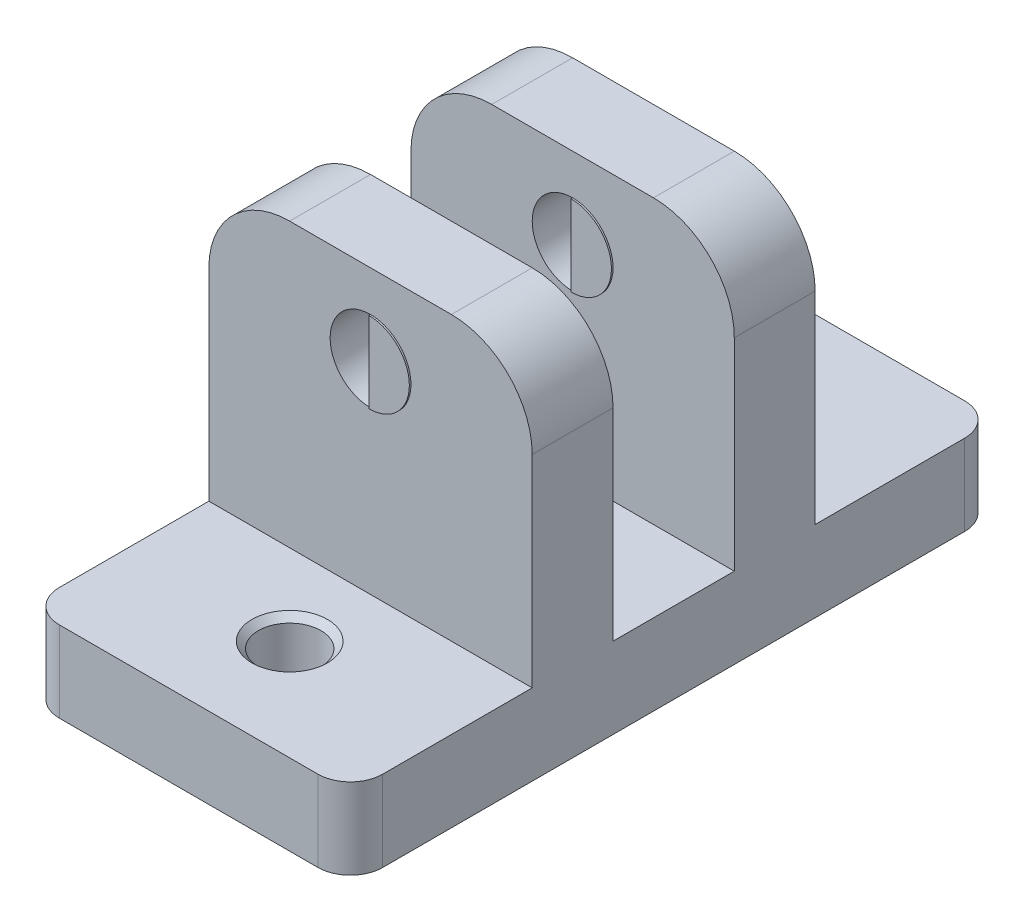
from build123d import *

# Parameters (mm, degrees)
SKETCH2_W                        = 25.4
SKETCH2_H                        = 50.8
BOSS_EXTRUDE2_DEPTH              = 28.575
SKETCH3_W                        = 14.2875
SKETCH3_H                        = 22.225
SKETCH3_W_2                      = 9.525
CUT_EXTRUDE1_DEPTH               = 26.4
F_10_0_1935_DIAMETER_HOLE1_D     = 4.9149
F_10_0_1935_DIAMETER_HOLE1_DEPTH = 6.35
F_10_0_1935_DIAMETER_HOLE1_TIP   = 1.476584928
SKETCH8_R                        = 3.175
CUT_EXTRUDE3_DEPTH               = 37.5125
FILLET1_R                        = 6.35
FILLET2_R                        = 2.54
CHAMFER1_SIZE                    = 0.508
BOSS_EXTRUDE3_DEPTH              = 3.302


with BuildPart() as part:
    # Sketch2 → Boss-Extrude2 (new body)
    with BuildSketch(Plane(origin=(0, 0, 0), x_dir=(1, 0, 0), z_dir=(0, 1, 0))):
        Rectangle(SKETCH2_W, SKETCH2_H)
    extrude(amount=BOSS_EXTRUDE2_DEPTH)

    # Sketch3 → Cut-Extrude1 (cut, through all)
    with BuildSketch(Plane(origin=(12.7, 0, 0), x_dir=(0, 0, -1), z_dir=(1, 0, 0))):
        with Locations((-18.25625, 17.4625)):
            Rectangle(SKETCH3_W, SKETCH3_H)
        with Locations((18.25625, 17.4625)):
            Rectangle(SKETCH3_W, SKETCH3_H)
        with Locations((0, 17.4625)):
            Rectangle(SKETCH3_W_2, SKETCH3_H)
    extrude(amount=-CUT_EXTRUDE1_DEPTH, mode=Mode.SUBTRACT)

    # #10 (0.1935) Diameter Hole1
    with Locations(Plane(origin=(0, 6.35, 0), x_dir=(1, 0, 0), z_dir=(0, 1, 0))):
        with Locations((0, -17.4625), (0, 17.4625)):
            Hole(F_10_0_1935_DIAMETER_HOLE1_D / 2, depth=F_10_0_1935_DIAMETER_HOLE1_DEPTH)
            with Locations((0, 0, -(F_10_0_1935_DIAMETER_HOLE1_DEPTH + F_10_0_1935_DIAMETER_HOLE1_TIP / 2))):  # 118° drill point
                Cone(0, F_10_0_1935_DIAMETER_HOLE1_D / 2, F_10_0_1935_DIAMETER_HOLE1_TIP, mode=Mode.SUBTRACT)

    # Sketch8 → Cut-Extrude3 (cut, through all)
    with BuildSketch(Plane(origin=(0, 0, -11.1125), x_dir=(-1, 0, 0), z_dir=(0, 0, -1))):
        with Locations((0, 22.225)):
            Circle(SKETCH8_R)
    extrude(amount=-CUT_EXTRUDE3_DEPTH, mode=Mode.SUBTRACT)

    # Fillet1
    fillet1_edges = [part.edges().sort_by_distance(p)[0] for p in [
        (12.7, 28.575, 7.9375),
        (-12.7, 28.575, -7.9375),
        (-12.7, 28.575, 7.9375),
        (12.7, 28.575, -7.9375),
    ]]
    fillet(fillet1_edges, radius=FILLET1_R)

    # Fillet2
    fillet2_edges = [part.edges().sort_by_distance(p)[0] for p in [
        (12.7, 3.175, 25.4),
        (-12.7, 3.175, 25.4),
        (-12.7, 3.175, -25.4),
        (12.7, 3.175, -25.4),
    ]]
    fillet(fillet2_edges, radius=FILLET2_R)

    # Chamfer1
    chamfer1_edges = [part.edges().sort_by_distance(p)[0] for p in [
        (2.45745, 6.35, -17.4625),
        (2.45745, 0, -17.4625),
        (2.45745, 6.35, 17.4625),
        (2.45745, 0, 17.4625),
    ]]
    chamfer(chamfer1_edges, length=CHAMFER1_SIZE)

    # Sketch10 → Boss-Extrude3 (add, symmetric)
    with BuildSketch(Plane(origin=(0, 0, -7.9375), x_dir=(-1, 0, 0), z_dir=(0, 0, -1))):
        with BuildLine():
            Line((0, 25.4), (0, 19.05))
            ThreePointArc((0, 19.05), (-3.175, 22.225), (0, 25.4))
        make_face()
    boss_extrude3 = extrude(amount=BOSS_EXTRUDE3_DEPTH, both=True)

    # Mirror1: Boss-Extrude3 across plane
    add(boss_extrude3.mirror(Plane.XY))


solid = part.part
